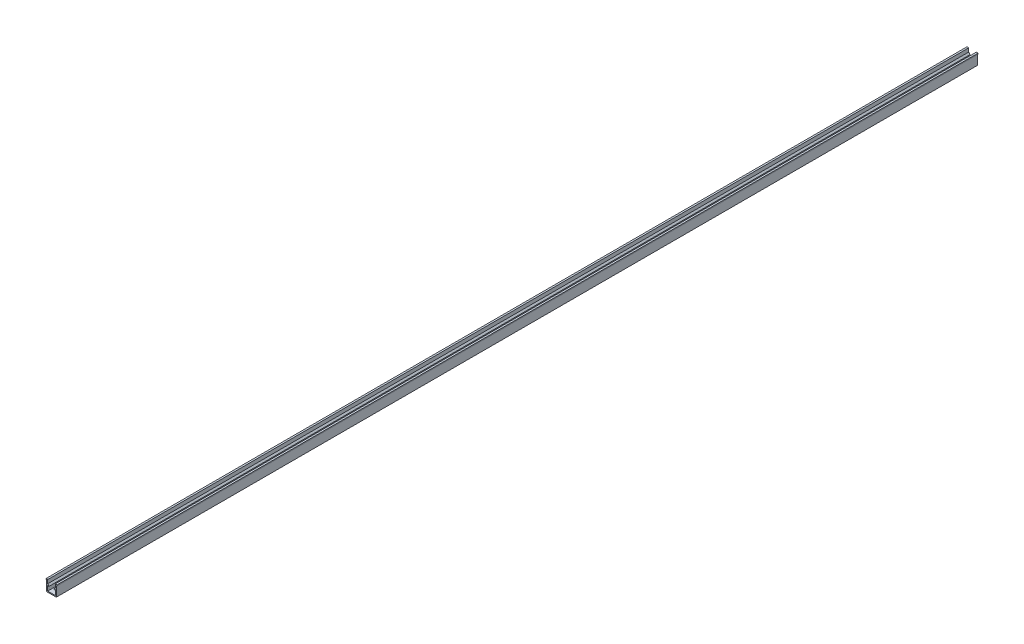
from build123d import *

# Parameters (mm, degrees)
EXTRUDE_1_DEPTH = 1000


with BuildPart() as part:
    # Эскиз1 → Бобышка-Вытянуть1 (new body)
    with BuildSketch(Plane.XY):
        Polygon((5.2, 0), (-5.2, 0), (-5.2, 11), (-6, 11), (-6, 12), (-4.1, 12), (-4.1, 8), (-2.544365081, 6.444365081), (-3.251471863, 5.7372583), (-4.1, 6.585786438), (-4.1, 1.1), (4.1, 1.1), (4.1, 6.585786438), (3.251471863, 5.7372583), (2.544365081, 6.444365081), (4.1, 8), (4.1, 12), (6, 12), (6, 11), (5.2, 11), align=None)
    extrude(amount=EXTRUDE_1_DEPTH)


solid = part.part
